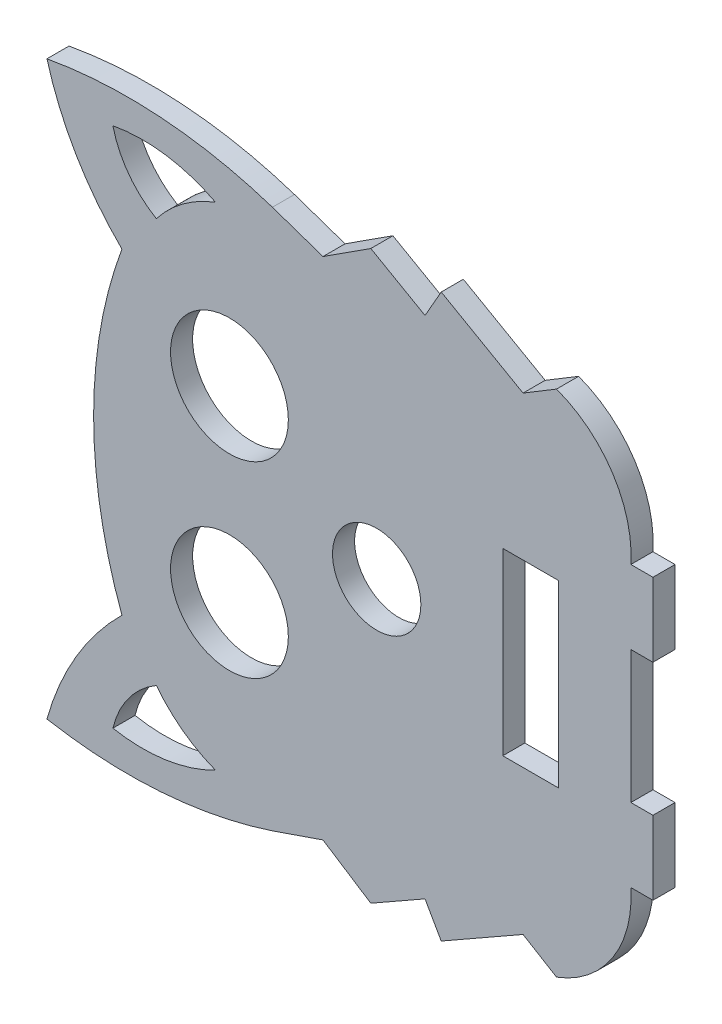
from build123d import *

# Parameters (mm, degrees)
SKETCH2_R           = 8
SKETCH2_R_2         = 6
SKETCH2_W           = 7.6
SKETCH2_H           = 24.4
BOSS_EXTRUDE1_DEPTH = 3


with BuildPart() as part:
    # Sketch2 → Boss-Extrude1 (new body)
    with BuildSketch(Plane.XY):
        with BuildLine():
            Line((81.032103119, 50.181312), (81.032103119, 60.181312))
            Line((81.032103119, 60.181312), (78.032103119, 60.181312))
            ThreePointArc((78.032103119, 60.181312), (75.569321499, 69.649967364), (67.936161846, 75.770065518))
            Line((67.936161846, 75.770065518), (63.389132962, 73.023833254))
            Line((63.389132962, 73.023833254), (52.27464227, 79.356930255))
            Line((52.27464227, 79.356930255), (50.074247047, 75.495269488))
            Line((50.074247047, 75.495269488), (42.709956252, 79.691482274))
            Line((42.709956252, 79.691482274), (36.212476018, 75.495269488))
            Line((36.212476018, 75.495269488), (29.342622159, 77.861804263))
            ThreePointArc((29.342622159, 77.861804263), (14.166162437, 80.849682425), (-1.279201176, 80.017163065))
            ThreePointArc((-1.279201176, 80.017163065), (2.677054283, 70.700200378), (8.902417187, 62.718809041))
            ThreePointArc((8.902417187, 62.718809041), (5.05730693, 41.181312), (8.902417187, 19.643814959))
            ThreePointArc((8.902417187, 19.643814959), (2.677054283, 11.662423622), (-1.279201176, 2.345460935))
            ThreePointArc((-1.279201176, 2.345460935), (14.166162437, 1.512941575), (29.342622159, 4.500819737))
            Line((29.342622159, 4.500819737), (36.212476018, 6.867354512))
            Line((36.212476018, 6.867354512), (42.709956252, 2.671141726))
            Line((42.709956252, 2.671141726), (50.074247047, 6.867354512))
            Line((50.074247047, 6.867354512), (52.27464227, 3.005693745))
            Line((52.27464227, 3.005693745), (63.389132962, 9.338790746))
            Line((63.389132962, 9.338790746), (67.936161846, 6.592558482))
            ThreePointArc((67.936161846, 6.592558482), (75.569321499, 12.712656636), (78.032103119, 22.181312))
            Line((78.032103119, 22.181312), (81.032103119, 22.181312))
            Line((81.032103119, 22.181312), (81.032103119, 32.181312))
            Line((81.032103119, 32.181312), (78.032103119, 32.181312))
            Line((78.032103119, 32.181312), (78.032103119, 50.181312))
            Line((78.032103119, 50.181312), (81.032103119, 50.181312))
        make_face()
        with Locations((23.507028058, 53.931312)):
            Circle(SKETCH2_R, mode=Mode.SUBTRACT)
        with Locations((43.507028058, 41.181312)):
            Circle(SKETCH2_R_2, mode=Mode.SUBTRACT)
        with Locations((23.507028058, 28.431312)):
            Circle(SKETCH2_R, mode=Mode.SUBTRACT)
        with Locations((64.432028058, 41.181312)):
            Rectangle(SKETCH2_W, SKETCH2_H, mode=Mode.SUBTRACT)
        with BuildLine():
            ThreePointArc((21.611730632, 74.586477389), (14.814545044, 76.765459524), (7.678288301, 76.612049032))
            ThreePointArc((7.678288301, 76.612049032), (9.811410227, 72.018941841), (13.580912618, 68.636975763))
            ThreePointArc((13.580912618, 68.636975763), (17.183726984, 72.168659356), (21.611730632, 74.586477389))
        make_face(mode=Mode.SUBTRACT)
        with BuildLine():
            ThreePointArc((7.678288301, 5.750574968), (9.811410227, 10.343682159), (13.580912618, 13.725648237))
            ThreePointArc((13.580912618, 13.725648237), (17.183726984, 10.193964644), (21.611730632, 7.776146611))
            ThreePointArc((21.611730632, 7.776146611), (14.814545044, 5.597164476), (7.678288301, 5.750574968))
        make_face(mode=Mode.SUBTRACT)
    extrude(amount=BOSS_EXTRUDE1_DEPTH)


solid = part.part
